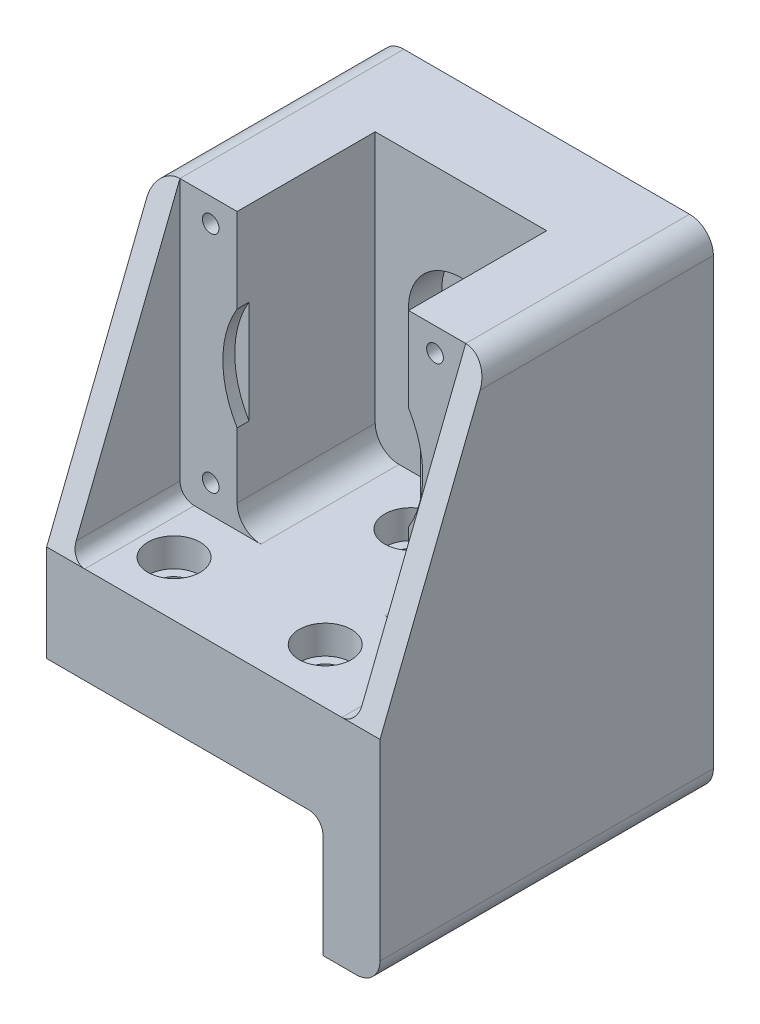
from build123d import *

# Parameters (mm, degrees)
SKETCH1_R                                       = 1.75
SKETCH1_R_2                                     = 6
BOSS_EXTRUDE1_DEPTH                             = 70
SKETCH2_W                                       = 36
SKETCH2_H                                       = 58
CUT_EXTRUDE1_DEPTH                              = 52
SKETCH3_W                                       = 60
SKETCH3_H                                       = 58
CUT_EXTRUDE2_DEPTH                              = 23
SKETCH4_R                                       = 21
CUT_EXTRUDE3_DEPTH                              = 2.5
FILLET2_R                                       = 5
FILLET3_R                                       = 3
SKETCH5_R                                       = 11.025
CUT_EXTRUDE4_DEPTH                              = 7
CBORE_FOR_M6_SOCKET_HEAD_CAP_SCREW1_D           = 7
CBORE_FOR_M6_SOCKET_HEAD_CAP_SCREW1_CBORE_D     = 11
CBORE_FOR_M6_SOCKET_HEAD_CAP_SCREW1_CBORE_DEPTH = 6
SKETCH8_W                                       = 59.674444403
SKETCH8_H                                       = 31.446844148
CUT_EXTRUDE5_DEPTH                              = 71.0000001
CUT_EXTRUDE6_DEPTH                              = 36
CUT_EXTRUDE6_DEPTH_BACK                         = 36
CHAMFER1_SIZE                                   = 1


with BuildPart() as part:
    # Sketch1 → Boss-Extrude1 (new body)
    with BuildSketch(Plane.XY):
        Polygon((-35, -74.75), (-35, 28.55), (35, 28.55), (35, -74.75), (23, -74.75), (23, -49.75), (-23, -49.75), (-23, -74.75), align=None)
        with Locations((-23.55, 23.55)):
            Circle(SKETCH1_R, mode=Mode.SUBTRACT)
        with Locations((23.55, -23.55)):
            Circle(SKETCH1_R, mode=Mode.SUBTRACT)
        with Locations((23.55, 23.55)):
            Circle(SKETCH1_R, mode=Mode.SUBTRACT)
        with Locations((-23.55, -23.55)):
            Circle(SKETCH1_R, mode=Mode.SUBTRACT)
        Circle(SKETCH1_R_2, mode=Mode.SUBTRACT)
    extrude(amount=BOSS_EXTRUDE1_DEPTH)

    # Sketch2 → Cut-Extrude1 (cut)
    with BuildSketch(Plane.XY.offset(70)):
        with Locations((0, -0.45)):
            Rectangle(SKETCH2_W, SKETCH2_H)
    extrude(amount=-CUT_EXTRUDE1_DEPTH, mode=Mode.SUBTRACT)

    # Sketch3 → Cut-Extrude2 (cut)
    with BuildSketch(Plane.XY.offset(70)):
        with Locations((0, -0.45)):
            Rectangle(SKETCH3_W, SKETCH3_H)
    extrude(amount=-CUT_EXTRUDE2_DEPTH, mode=Mode.SUBTRACT)

    # Sketch4 → Cut-Extrude3 (cut)
    with BuildSketch(Plane.XY.offset(47)):
        Circle(SKETCH4_R)
    extrude(amount=-CUT_EXTRUDE3_DEPTH, mode=Mode.SUBTRACT)

    # Fillet2
    fillet2_edges = [part.edges().sort_by_distance(p)[0] for p in [
        (35, -74.75, 35),
        (-35, -74.75, 35),
        (35, 28.55, 35),
        (-35, 28.55, 35),
        (18, -29.45, 32.5),
        (-18, -29.45, 32.5),
    ]]
    fillet(fillet2_edges, radius=FILLET2_R)

    # Fillet3
    fillet3_edges = [part.edges().sort_by_distance(p)[0] for p in [
        (23, -49.75, 35),
        (-23, -49.75, 35),
        (30, -29.45, 58.5),
        (-30, -29.45, 58.5),
    ]]
    fillet(fillet3_edges, radius=FILLET3_R)

    # Sketch5 → Cut-Extrude4 (cut)
    with BuildSketch(Plane.XY.offset(18)):
        Circle(SKETCH5_R)
    extrude(amount=-CUT_EXTRUDE4_DEPTH, mode=Mode.SUBTRACT)

    # CBORE for M6 Socket Head Cap Screw1 (through all)
    with Locations(Plane(origin=(0, -29.45, 0), x_dir=(1, 0, 0), z_dir=(0, 1, 0))):
        with Locations((0, -28.5), (-19.75, -58.5), (12, -58.5)):
            CounterBoreHole(CBORE_FOR_M6_SOCKET_HEAD_CAP_SCREW1_D / 2, CBORE_FOR_M6_SOCKET_HEAD_CAP_SCREW1_CBORE_D / 2, CBORE_FOR_M6_SOCKET_HEAD_CAP_SCREW1_CBORE_DEPTH)

    # Sketch8 → Cut-Extrude5 (cut, through all)
    with BuildSketch(Plane.XY.offset(70)):
        with Locations((-33.952701125, -65.473422074)):
            Rectangle(SKETCH8_W, SKETCH8_H)
    extrude(amount=-CUT_EXTRUDE5_DEPTH, mode=Mode.SUBTRACT)

    # Sketch9 → Cut-Extrude6 (cut, two sides)
    with BuildSketch(Plane(origin=(0, 0, 0), x_dir=(0, 0, -1), z_dir=(1, 0, 0))) as cut_extrude6_sk:
        Polygon((-47, 28.55), (-70, 28.55), (-70, -29.45), align=None)
    extrude(amount=CUT_EXTRUDE6_DEPTH, mode=Mode.SUBTRACT)
    extrude(cut_extrude6_sk.sketch, amount=-CUT_EXTRUDE6_DEPTH_BACK, mode=Mode.SUBTRACT)

    # Chamfer1
    chamfer1_edges = [part.edges().sort_by_distance(p)[0] for p in [
        (-6, 0, 11),
    ]]
    chamfer(chamfer1_edges, length=CHAMFER1_SIZE)


solid = part.part
